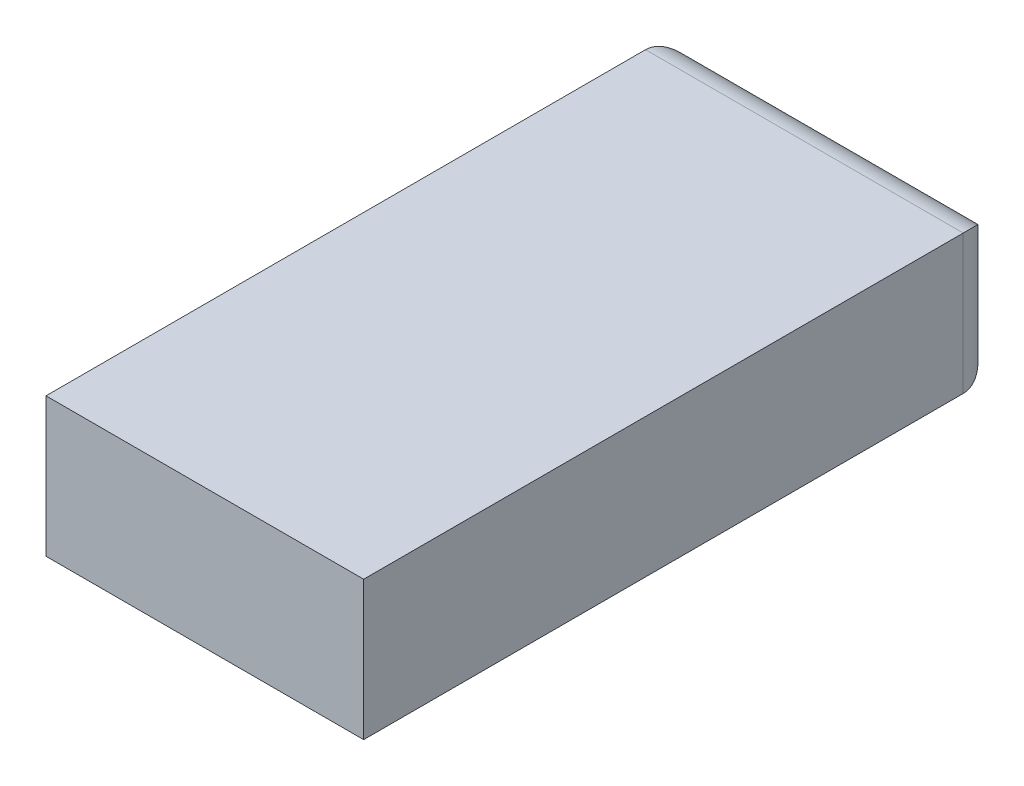
from build123d import *

# Parameters (mm, degrees)
SKETCH1_W           = 101.6
SKETCH1_H           = 203.2
BOSS_EXTRUDE1_DEPTH = 44.45
FILLET1_R           = 11.43


with BuildPart() as part:
    # Sketch1 → Boss-Extrude1 (new body)
    with BuildSketch(Plane(origin=(0, 0, 0), x_dir=(1, 0, 0), z_dir=(0, 1, 0))):
        Rectangle(SKETCH1_W, SKETCH1_H)
    extrude(amount=BOSS_EXTRUDE1_DEPTH)

    # Fillet1
    fillet1_edges = [part.edges().sort_by_distance(p)[0] for p in [
        (0, 0, -101.6),
        (-50.8, 22.225, -101.6),
        (50.8, 22.225, -101.6),
        (0, 44.45, -101.6),
    ]]
    fillet(fillet1_edges, radius=FILLET1_R)


solid = part.part
